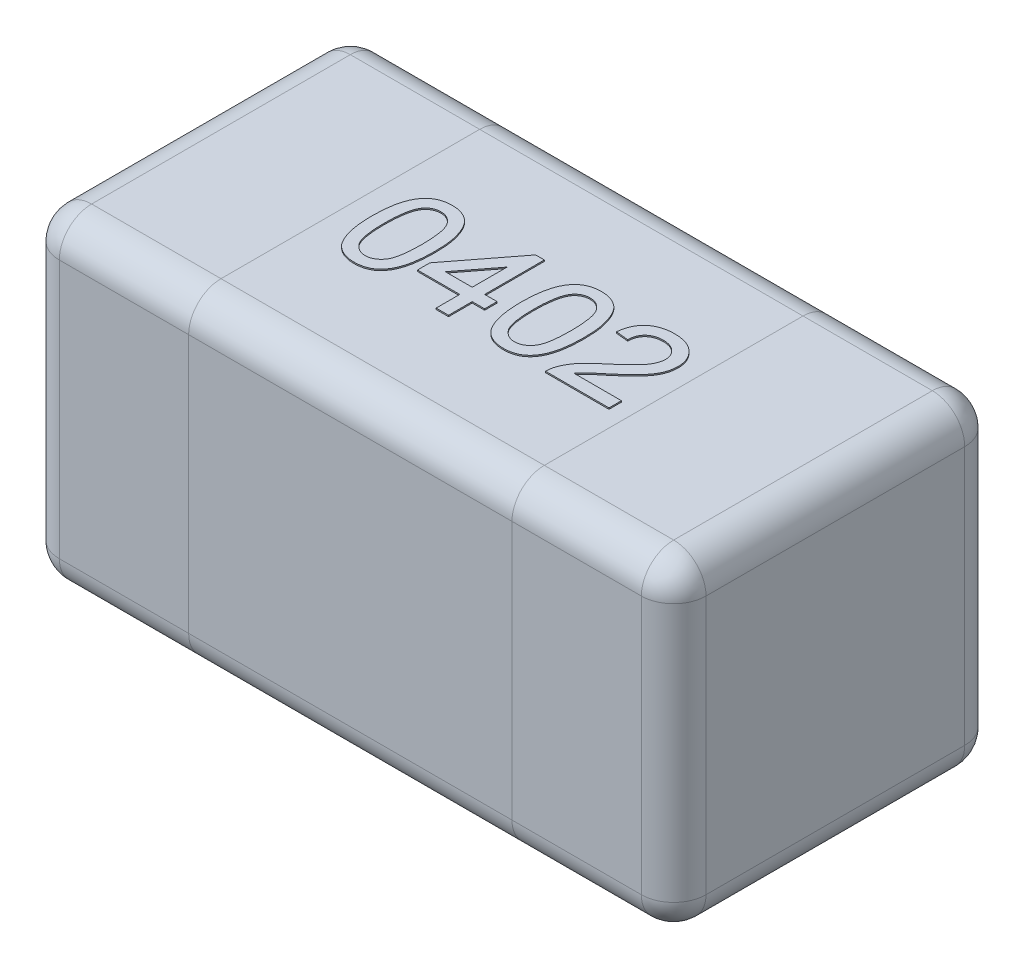
from build123d import *

# Parameters (mm, degrees)
SKETCH1_W      = 1
SKETCH1_H      = 0.5
EXTRUDE1_DEPTH = 0.5
FILLET1_R      = 0.05
EXTRUDE2_DEPTH = 0.002


with BuildPart() as part:
    # Sketch1 → Extrude1 (new body)
    with BuildSketch(Plane(origin=(0, 0, 0), x_dir=(1, 0, 0), z_dir=(0, 1, 0))):
        Rectangle(SKETCH1_W, SKETCH1_H)
    extrude(amount=EXTRUDE1_DEPTH)

    # Fillet1
    fillet1_edges = [part.edges().sort_by_distance(p)[0] for p in [
        (0.5, 0.5, 0),
        (0, 0.5, -0.25),
        (-0.5, 0.5, 0),
        (0, 0, -0.25),
        (0.5, 0, 0),
        (0, 0, 0.25),
        (-0.5, 0, 0),
        (0, 0.5, 0.25),
        (-0.5, 0.25, -0.25),
        (0.5, 0.25, -0.25),
        (0.5, 0.25, 0.25),
        (-0.5, 0.25, 0.25),
    ]]
    fillet(fillet1_edges, radius=FILLET1_R)

    # Sketch3 → Extrude2 (add)
    with BuildSketch(Plane(origin=(0, 0.5, 0), x_dir=(1, 0, 0), z_dir=(0, 1, 0))):
        with BuildLine():
            add(Edge.make_bspline(
                [(-0.215384615, -0.001021635), (-0.21536524, 0.001122003), (-0.215327293, 0.005320487), (-0.215091917, 0.011463622), (-0.21468097, 0.017297504), (-0.214067539, 0.022817065), (-0.213341122, 0.028034764), (-0.212396775, 0.032943155), (-0.211334247, 0.037553251), (-0.210059405, 0.041860246), (-0.20865877, 0.045901174), (-0.207069705, 0.04966955), (-0.205281792, 0.053161381), (-0.203382895, 0.056412877), (-0.201273053, 0.059373466), (-0.19907961, 0.062126232), (-0.196643162, 0.064570222), (-0.19406502, 0.06676832), (-0.191307221, 0.068708013), (-0.188384356, 0.070381735), (-0.185307672, 0.07185951), (-0.182018531, 0.072971978), (-0.178585214, 0.073878876), (-0.174981294, 0.074546001), (-0.171202799, 0.074939294), (-0.168620729, 0.074979536), (-0.167307692, 0.075)],
                knots=[0, 0, 0, 0, 6.431e-06, 1.2595e-05, 1.844e-05, 2.3971e-05, 2.9254e-05, 3.4239e-05, 3.8962e-05, 4.344e-05, 4.7707e-05, 5.1787e-05, 5.5698e-05, 5.947e-05, 6.3071e-05, 6.6596e-05, 7.0016e-05, 7.3406e-05, 7.6749e-05, 8.0114e-05, 8.3502e-05, 8.697e-05, 9.0512e-05, 9.4149e-05, 9.7955e-05, 0.000101893, 0.000101893, 0.000101893, 0.000101893], degree=3))
            add(Edge.make_bspline(
                [(-0.167307692, 0.075), (-0.165381297, 0.074943365), (-0.161596815, 0.074832104), (-0.156071453, 0.073924679), (-0.150864154, 0.072372388), (-0.145978304, 0.070278281), (-0.141497424, 0.067618363), (-0.137495809, 0.064384826), (-0.134016624, 0.060611623), (-0.131097837, 0.056254042), (-0.128546526, 0.051432296), (-0.126279998, 0.046124741), (-0.124231122, 0.040337325), (-0.122777195, 0.035156781), (-0.12174011, 0.030684751), (-0.121053643, 0.026996347), (-0.120483737, 0.023016538), (-0.120047112, 0.018754953), (-0.119688871, 0.014216372), (-0.119412219, 0.009397968), (-0.119271789, 0.004287698), (-0.119244699, 0.000781321), (-0.119230769, -0.001021635)],
                knots=[0, 0, 0, 0, 5.777e-06, 1.1349e-05, 1.674e-05, 2.2043e-05, 2.7258e-05, 3.2321e-05, 3.7425e-05, 4.2592e-05, 4.801e-05, 5.377e-05, 5.9891e-05, 6.6416e-05, 6.99e-05, 7.366e-05, 7.7668e-05, 8.1958e-05, 8.651e-05, 9.1325e-05, 9.6435e-05, 0.000101844, 0.000101844, 0.000101844, 0.000101844], degree=3))
            add(Edge.make_bspline(
                [(-0.119230769, -0.001021635), (-0.119250507, -0.003155203), (-0.119289069, -0.00732355), (-0.119518138, -0.013417428), (-0.119953848, -0.019207296), (-0.120489996, -0.024706416), (-0.121301077, -0.029900109), (-0.12217506, -0.034810441), (-0.123255962, -0.039415115), (-0.12451712, -0.043716149), (-0.12593747, -0.047736285), (-0.127495104, -0.051505906), (-0.129220334, -0.055022436), (-0.131164508, -0.058251575), (-0.133238671, -0.061236186), (-0.135458016, -0.063987464), (-0.137869594, -0.066465811), (-0.140470969, -0.068657315), (-0.143209405, -0.070631406), (-0.146139376, -0.072321652), (-0.149248057, -0.073721992), (-0.152514679, -0.074919212), (-0.155972386, -0.075796465), (-0.159593911, -0.076467989), (-0.163392598, -0.07686343), (-0.165984655, -0.07690292), (-0.167307692, -0.076923077)],
                knots=[0, 0, 0, 0, 6.401e-06, 1.2505e-05, 1.829e-05, 2.3818e-05, 2.9075e-05, 3.4055e-05, 3.8778e-05, 4.3256e-05, 4.7495e-05, 5.1563e-05, 5.5487e-05, 5.9233e-05, 6.2859e-05, 6.6384e-05, 6.9826e-05, 7.3215e-05, 7.6576e-05, 7.9941e-05, 8.3343e-05, 8.6794e-05, 9.0365e-05, 9.4031e-05, 9.7837e-05, 0.000101805, 0.000101805, 0.000101805, 0.000101805], degree=3))
            add(Edge.make_bspline(
                [(-0.167307692, -0.076923077), (-0.169042347, -0.076873596), (-0.172424447, -0.076777121), (-0.177363754, -0.076121636), (-0.181999557, -0.074967951), (-0.186370957, -0.073420697), (-0.190428817, -0.071351156), (-0.194192513, -0.068833154), (-0.197737673, -0.065925277), (-0.199778482, -0.063631029), (-0.200811298, -0.062469952)],
                knots=[0, 0, 0, 0, 5.204e-06, 1.0146e-05, 1.4912e-05, 1.9513e-05, 2.4028e-05, 2.8537e-05, 3.308e-05, 3.7736e-05, 3.7736e-05, 3.7736e-05, 3.7736e-05], degree=3))
            add(Edge.make_bspline(
                [(-0.200811298, -0.062469952), (-0.202000093, -0.060755098), (-0.204451439, -0.057218995), (-0.207320527, -0.051189611), (-0.209879805, -0.044552107), (-0.211888368, -0.037176254), (-0.213461574, -0.029120757), (-0.214597822, -0.020369808), (-0.215240826, -0.010927188), (-0.215335604, -0.004398023), (-0.215384615, -0.001021635)],
                knots=[0, 0, 0, 0, 6.251e-06, 1.2889e-05, 1.9965e-05, 2.7576e-05, 3.5785e-05, 4.4573e-05, 5.4032e-05, 6.4161e-05, 6.4161e-05, 6.4161e-05, 6.4161e-05], degree=3))
        make_face()
        with BuildLine():
            add(Edge.make_bspline(
                [(-0.196153846, -0.000961538), (-0.196134752, -0.003846584), (-0.1960982, -0.009369199), (-0.195716327, -0.017259208), (-0.195058949, -0.024377073), (-0.194189852, -0.030712939), (-0.193042293, -0.036275377), (-0.191601396, -0.041050211), (-0.189977162, -0.045094751), (-0.187967204, -0.048358867), (-0.185766521, -0.051019598), (-0.183494467, -0.053307912), (-0.181097587, -0.055252927), (-0.178591522, -0.056874673), (-0.175937387, -0.058102553), (-0.173164205, -0.058992522), (-0.170271373, -0.059504686), (-0.168301222, -0.059578275), (-0.167307692, -0.059615385)],
                knots=[0, 0, 0, 0, 8.655e-06, 1.6567e-05, 2.3689e-05, 3.0093e-05, 3.5745e-05, 4.0706e-05, 4.5043e-05, 4.8779e-05, 5.2153e-05, 5.5383e-05, 5.8438e-05, 6.1397e-05, 6.4314e-05, 6.7184e-05, 7.0113e-05, 7.3094e-05, 7.3094e-05, 7.3094e-05, 7.3094e-05], degree=3))
            add(Edge.make_bspline(
                [(-0.167307692, -0.059615385), (-0.166314411, -0.059577464), (-0.164344754, -0.059502268), (-0.161445238, -0.059001397), (-0.158682846, -0.058065613), (-0.156032668, -0.05684207), (-0.153508388, -0.055257289), (-0.15112328, -0.053304927), (-0.148839257, -0.051017971), (-0.14664846, -0.048326314), (-0.144653815, -0.045047107), (-0.142999112, -0.041005862), (-0.141580671, -0.036222665), (-0.140426814, -0.030663062), (-0.139554132, -0.024337213), (-0.138900728, -0.01723909), (-0.1385163, -0.009359233), (-0.138480352, -0.003846597), (-0.138461538, -0.000961538)],
                knots=[0, 0, 0, 0, 2.98e-06, 5.91e-06, 8.789e-06, 1.1706e-05, 1.4649e-05, 1.7704e-05, 2.0934e-05, 2.4331e-05, 2.8093e-05, 3.2402e-05, 3.7392e-05, 4.3044e-05, 4.9418e-05, 5.654e-05, 6.4422e-05, 7.3077e-05, 7.3077e-05, 7.3077e-05, 7.3077e-05], degree=3))
            add(Edge.make_bspline(
                [(-0.138461538, -0.000961538), (-0.13847975, 0.001863491), (-0.138514642, 0.007276142), (-0.138908985, 0.015014149), (-0.139526956, 0.022012544), (-0.140372243, 0.028277777), (-0.141495628, 0.033803048), (-0.142858142, 0.038600117), (-0.144481781, 0.042658756), (-0.146412281, 0.046019733), (-0.148561315, 0.048776646), (-0.150806184, 0.051162994), (-0.153203011, 0.053192505), (-0.15579426, 0.054820609), (-0.15849641, 0.056134103), (-0.161371551, 0.057038082), (-0.164391421, 0.057593459), (-0.166463918, 0.057658982), (-0.167518029, 0.057692308)],
                knots=[0, 0, 0, 0, 8.474e-06, 1.6237e-05, 2.3236e-05, 2.9547e-05, 3.5192e-05, 4.0137e-05, 4.4489e-05, 4.8272e-05, 5.1722e-05, 5.4953e-05, 5.8088e-05, 6.1114e-05, 6.4111e-05, 6.7076e-05, 7.0129e-05, 7.329e-05, 7.329e-05, 7.329e-05, 7.329e-05], degree=3))
            add(Edge.make_bspline(
                [(-0.167518029, 0.057692308), (-0.168511496, 0.057666233), (-0.170470487, 0.057614817), (-0.173338706, 0.057124054), (-0.176056884, 0.056303389), (-0.178656161, 0.055191718), (-0.181071649, 0.053695629), (-0.18339914, 0.051948838), (-0.185529622, 0.049820569), (-0.186813432, 0.048229508), (-0.187469952, 0.047415865)],
                knots=[0, 0, 0, 0, 2.979e-06, 5.873e-06, 8.697e-06, 1.1482e-05, 1.4327e-05, 1.72e-05, 2.0196e-05, 2.3331e-05, 2.3331e-05, 2.3331e-05, 2.3331e-05], degree=3))
            add(Edge.make_bspline(
                [(-0.187469952, 0.047415865), (-0.188184701, 0.046220876), (-0.189694102, 0.043697311), (-0.191383033, 0.03931125), (-0.192874969, 0.034298818), (-0.194103326, 0.028582894), (-0.194991956, 0.022173284), (-0.195693496, 0.01507743), (-0.196057919, 0.007285427), (-0.196120988, 0.001863295), (-0.196153846, -0.000961538)],
                knots=[0, 0, 0, 0, 4.171e-06, 8.807e-06, 1.4046e-05, 1.9857e-05, 2.6324e-05, 3.3449e-05, 4.1242e-05, 4.9717e-05, 4.9717e-05, 4.9717e-05, 4.9717e-05], degree=3))
        make_face(mode=Mode.SUBTRACT)
        Polygon((-0.042307692, -0.075), (-0.042307692, -0.038461538), (-0.107692308, -0.038461538), (-0.107692308, -0.019230769), (-0.036538462, 0.073076923), (-0.023076923, 0.073076923), (-0.023076923, -0.019230769), (-0.003846154, -0.019230769), (-0.003846154, -0.038461538), (-0.023076923, -0.038461538), (-0.023076923, -0.075), align=None)
        Polygon((-0.042307692, -0.019230769), (-0.042307692, 0.034795673), (-0.083954327, -0.019230769), align=None, mode=Mode.SUBTRACT)
        with BuildLine():
            add(Edge.make_bspline(
                [(0.015384615, -0.001021635), (0.01540399, 0.001122003), (0.015441938, 0.005320487), (0.015677314, 0.011463622), (0.016088261, 0.017297504), (0.016701692, 0.022817065), (0.017428109, 0.028034764), (0.018372456, 0.032943155), (0.019434984, 0.037553251), (0.020709826, 0.041860246), (0.022110461, 0.045901174), (0.023699525, 0.04966955), (0.025487439, 0.053161381), (0.027386336, 0.056412877), (0.029496178, 0.059373466), (0.031689621, 0.062126232), (0.034126069, 0.064570222), (0.036704211, 0.06676832), (0.03946201, 0.068708013), (0.042384875, 0.070381735), (0.045461558, 0.07185951), (0.0487507, 0.072971978), (0.052184016, 0.073878876), (0.055787937, 0.074546001), (0.059566432, 0.074939294), (0.062148502, 0.074979536), (0.063461538, 0.075)],
                knots=[0, 0, 0, 0, 6.431e-06, 1.2595e-05, 1.844e-05, 2.3971e-05, 2.9254e-05, 3.4239e-05, 3.8962e-05, 4.344e-05, 4.7707e-05, 5.1787e-05, 5.5698e-05, 5.947e-05, 6.3071e-05, 6.6596e-05, 7.0016e-05, 7.3406e-05, 7.6749e-05, 8.0114e-05, 8.3502e-05, 8.697e-05, 9.0512e-05, 9.4149e-05, 9.7955e-05, 0.000101893, 0.000101893, 0.000101893, 0.000101893], degree=3))
            add(Edge.make_bspline(
                [(0.063461538, 0.075), (0.065387934, 0.074943365), (0.069172416, 0.074832104), (0.074697778, 0.073924679), (0.079905076, 0.072372388), (0.084790927, 0.070278281), (0.089271807, 0.067618363), (0.093273422, 0.064384826), (0.096752607, 0.060611623), (0.099671394, 0.056254042), (0.102222704, 0.051432296), (0.104489233, 0.046124741), (0.106538109, 0.040337325), (0.107992036, 0.035156781), (0.10902912, 0.030684751), (0.109715588, 0.026996347), (0.110285494, 0.023016538), (0.110722119, 0.018754953), (0.111080359, 0.014216372), (0.111357012, 0.009397968), (0.111497442, 0.004287698), (0.111524532, 0.000781321), (0.111538462, -0.001021635)],
                knots=[0, 0, 0, 0, 5.777e-06, 1.1349e-05, 1.674e-05, 2.2043e-05, 2.7258e-05, 3.2321e-05, 3.7425e-05, 4.2592e-05, 4.801e-05, 5.377e-05, 5.9891e-05, 6.6416e-05, 6.99e-05, 7.366e-05, 7.7668e-05, 8.1958e-05, 8.651e-05, 9.1325e-05, 9.6435e-05, 0.000101844, 0.000101844, 0.000101844, 0.000101844], degree=3))
            add(Edge.make_bspline(
                [(0.111538462, -0.001021635), (0.111518724, -0.003155203), (0.111480162, -0.00732355), (0.111251093, -0.013417428), (0.110815383, -0.019207296), (0.110279235, -0.024706416), (0.109468154, -0.029900109), (0.108594171, -0.034810441), (0.107513269, -0.039415115), (0.106252111, -0.043716149), (0.10483176, -0.047736285), (0.103274126, -0.051505906), (0.101548897, -0.055022436), (0.099604723, -0.058251575), (0.097530559, -0.061236186), (0.095311215, -0.063987464), (0.092899636, -0.066465811), (0.090298262, -0.068657315), (0.087559826, -0.070631406), (0.084629855, -0.072321652), (0.081521174, -0.073721992), (0.078254552, -0.074919212), (0.074796845, -0.075796465), (0.07117532, -0.076467989), (0.067376633, -0.07686343), (0.064784575, -0.07690292), (0.063461538, -0.076923077)],
                knots=[0, 0, 0, 0, 6.401e-06, 1.2505e-05, 1.829e-05, 2.3818e-05, 2.9075e-05, 3.4055e-05, 3.8778e-05, 4.3256e-05, 4.7495e-05, 5.1563e-05, 5.5487e-05, 5.9233e-05, 6.2859e-05, 6.6384e-05, 6.9826e-05, 7.3215e-05, 7.6576e-05, 7.9941e-05, 8.3343e-05, 8.6794e-05, 9.0365e-05, 9.4031e-05, 9.7837e-05, 0.000101805, 0.000101805, 0.000101805, 0.000101805], degree=3))
            add(Edge.make_bspline(
                [(0.063461538, -0.076923077), (0.061726884, -0.076873596), (0.058344784, -0.076777121), (0.053405477, -0.076121636), (0.048769674, -0.074967951), (0.044398274, -0.073420697), (0.040340414, -0.071351156), (0.036576718, -0.068833154), (0.033031558, -0.065925277), (0.030990749, -0.063631029), (0.029957933, -0.062469952)],
                knots=[0, 0, 0, 0, 5.204e-06, 1.0146e-05, 1.4912e-05, 1.9513e-05, 2.4028e-05, 2.8537e-05, 3.308e-05, 3.7736e-05, 3.7736e-05, 3.7736e-05, 3.7736e-05], degree=3))
            add(Edge.make_bspline(
                [(0.029957933, -0.062469952), (0.028769138, -0.060755098), (0.026317792, -0.057218995), (0.023448703, -0.051189611), (0.020889426, -0.044552107), (0.018880862, -0.037176254), (0.017307656, -0.029120757), (0.016171409, -0.020369808), (0.015528405, -0.010927188), (0.015433627, -0.004398023), (0.015384615, -0.001021635)],
                knots=[0, 0, 0, 0, 6.251e-06, 1.2889e-05, 1.9965e-05, 2.7576e-05, 3.5785e-05, 4.4573e-05, 5.4032e-05, 6.4161e-05, 6.4161e-05, 6.4161e-05, 6.4161e-05], degree=3))
        make_face()
        with BuildLine():
            add(Edge.make_bspline(
                [(0.034615385, -0.000961538), (0.034634479, -0.003846584), (0.034671031, -0.009369199), (0.035052903, -0.017259208), (0.035710281, -0.024377073), (0.036579378, -0.030712939), (0.037726938, -0.036275377), (0.039167835, -0.041050211), (0.040792069, -0.045094751), (0.042802027, -0.048358867), (0.04500271, -0.051019598), (0.047274764, -0.053307912), (0.049671644, -0.055252927), (0.052177709, -0.056874673), (0.054831844, -0.058102553), (0.057605026, -0.058992522), (0.060497858, -0.059504686), (0.062468008, -0.059578275), (0.063461538, -0.059615385)],
                knots=[0, 0, 0, 0, 8.655e-06, 1.6567e-05, 2.3689e-05, 3.0093e-05, 3.5745e-05, 4.0706e-05, 4.5043e-05, 4.8779e-05, 5.2153e-05, 5.5383e-05, 5.8438e-05, 6.1397e-05, 6.4314e-05, 6.7184e-05, 7.0113e-05, 7.3094e-05, 7.3094e-05, 7.3094e-05, 7.3094e-05], degree=3))
            add(Edge.make_bspline(
                [(0.063461538, -0.059615385), (0.06445482, -0.059577464), (0.066424477, -0.059502268), (0.069323993, -0.059001397), (0.072086385, -0.058065613), (0.074736563, -0.05684207), (0.077260843, -0.055257289), (0.079645951, -0.053304927), (0.081929974, -0.051017971), (0.084120771, -0.048326314), (0.086115416, -0.045047107), (0.087770119, -0.041005862), (0.08918856, -0.036222665), (0.090342417, -0.030663062), (0.091215099, -0.024337213), (0.091868502, -0.01723909), (0.092252931, -0.009359233), (0.092288879, -0.003846597), (0.092307692, -0.000961538)],
                knots=[0, 0, 0, 0, 2.98e-06, 5.91e-06, 8.789e-06, 1.1706e-05, 1.4649e-05, 1.7704e-05, 2.0934e-05, 2.4331e-05, 2.8093e-05, 3.2402e-05, 3.7392e-05, 4.3044e-05, 4.9418e-05, 5.654e-05, 6.4422e-05, 7.3077e-05, 7.3077e-05, 7.3077e-05, 7.3077e-05], degree=3))
            add(Edge.make_bspline(
                [(0.092307692, -0.000961538), (0.092289481, 0.001863491), (0.092254589, 0.007276142), (0.091860246, 0.015014149), (0.091242275, 0.022012544), (0.090396988, 0.028277777), (0.089273602, 0.033803048), (0.087911089, 0.038600117), (0.08628745, 0.042658756), (0.084356949, 0.046019733), (0.082207916, 0.048776646), (0.079963047, 0.051162994), (0.07756622, 0.053192505), (0.074974971, 0.054820609), (0.07227282, 0.056134103), (0.06939768, 0.057038082), (0.06637781, 0.057593459), (0.064305312, 0.057658982), (0.063251202, 0.057692308)],
                knots=[0, 0, 0, 0, 8.474e-06, 1.6237e-05, 2.3236e-05, 2.9547e-05, 3.5192e-05, 4.0137e-05, 4.4489e-05, 4.8272e-05, 5.1722e-05, 5.4953e-05, 5.8088e-05, 6.1114e-05, 6.4111e-05, 6.7076e-05, 7.0129e-05, 7.329e-05, 7.329e-05, 7.329e-05, 7.329e-05], degree=3))
            add(Edge.make_bspline(
                [(0.063251202, 0.057692308), (0.062257734, 0.057666233), (0.060298744, 0.057614817), (0.057430524, 0.057124054), (0.054712347, 0.056303389), (0.052113069, 0.055191718), (0.049697582, 0.053695629), (0.047370091, 0.051948838), (0.045239608, 0.049820569), (0.043955798, 0.048229508), (0.043299279, 0.047415865)],
                knots=[0, 0, 0, 0, 2.979e-06, 5.873e-06, 8.697e-06, 1.1482e-05, 1.4327e-05, 1.72e-05, 2.0196e-05, 2.3331e-05, 2.3331e-05, 2.3331e-05, 2.3331e-05], degree=3))
            add(Edge.make_bspline(
                [(0.043299279, 0.047415865), (0.042584529, 0.046220876), (0.041075129, 0.043697311), (0.039386197, 0.03931125), (0.037894262, 0.034298818), (0.036665905, 0.028582894), (0.035777274, 0.022173284), (0.035075735, 0.01507743), (0.034711312, 0.007285427), (0.034648242, 0.001863295), (0.034615385, -0.000961538)],
                knots=[0, 0, 0, 0, 4.171e-06, 8.807e-06, 1.4046e-05, 1.9857e-05, 2.6324e-05, 3.3449e-05, 4.1242e-05, 4.9717e-05, 4.9717e-05, 4.9717e-05, 4.9717e-05], degree=3))
        make_face(mode=Mode.SUBTRACT)
        with BuildLine():
            Line((0.225, -0.055769231), (0.225, -0.075))
            Line((0.225, -0.075), (0.126923077, -0.075))
            add(Edge.make_bspline(
                [(0.126923077, -0.075), (0.126921069, -0.073857061), (0.12691706, -0.071575015), (0.127303219, -0.068200013), (0.127908021, -0.064869783), (0.128591871, -0.062734239), (0.128936298, -0.061658654)],
                knots=[0, 0, 0, 0, 3.426e-06, 6.841e-06, 1.0176e-05, 1.3561e-05, 1.3561e-05, 1.3561e-05, 1.3561e-05], degree=3))
            add(Edge.make_bspline(
                [(0.128936298, -0.061658654), (0.129572684, -0.059901276), (0.130868472, -0.056322964), (0.133493751, -0.051159961), (0.136581699, -0.046028182), (0.139588252, -0.04185019), (0.142341605, -0.038512266), (0.14465065, -0.035900727), (0.147209495, -0.033227509), (0.150016092, -0.030493101), (0.153043427, -0.027679792), (0.156295632, -0.0247782), (0.159811111, -0.021842401), (0.162265283, -0.019896431), (0.163521635, -0.01890024)],
                knots=[0, 0, 0, 0, 5.603e-06, 1.1408e-05, 1.7339e-05, 2.356e-05, 2.6827e-05, 3.0318e-05, 3.4016e-05, 3.7925e-05, 4.2071e-05, 4.6413e-05, 5.0999e-05, 5.5809e-05, 5.5809e-05, 5.5809e-05, 5.5809e-05], degree=3))
            add(Edge.make_bspline(
                [(0.163521635, -0.01890024), (0.1654517, -0.017275735), (0.169168165, -0.014147648), (0.174416395, -0.009505855), (0.179209799, -0.005195689), (0.183472047, -0.001141602), (0.187238, 0.002617081), (0.1905165, 0.006071846), (0.193335758, 0.009211911), (0.195661355, 0.012150933), (0.197623532, 0.014926186), (0.199286304, 0.017633275), (0.200672004, 0.020319486), (0.201826106, 0.022976319), (0.202738903, 0.025615135), (0.203361104, 0.028243623), (0.203783059, 0.030835702), (0.203825276, 0.0325605), (0.203846154, 0.033413462)],
                knots=[0, 0, 0, 0, 7.568e-06, 1.4572e-05, 2.1018e-05, 2.6906e-05, 3.2217e-05, 3.6978e-05, 4.1193e-05, 4.4872e-05, 4.8215e-05, 5.1384e-05, 5.4395e-05, 5.7275e-05, 6.0069e-05, 6.2758e-05, 6.5371e-05, 6.7928e-05, 6.7928e-05, 6.7928e-05, 6.7928e-05], degree=3))
            add(Edge.make_bspline(
                [(0.203846154, 0.033413462), (0.203825274, 0.034256471), (0.203784308, 0.035910411), (0.20339563, 0.03833094), (0.202854559, 0.040661969), (0.201979812, 0.042861531), (0.2009386, 0.044994766), (0.199602994, 0.046994266), (0.198057972, 0.048909863), (0.196289053, 0.050691052), (0.194356979, 0.052362092), (0.192198162, 0.053751132), (0.189954391, 0.055001681), (0.18754826, 0.056007195), (0.184983678, 0.056745562), (0.182279313, 0.057281426), (0.179435596, 0.057621193), (0.177494958, 0.057668243), (0.176502404, 0.057692308)],
                knots=[0, 0, 0, 0, 2.527e-06, 4.958e-06, 7.341e-06, 9.69e-06, 1.2042e-05, 1.445e-05, 1.6886e-05, 1.9414e-05, 2.1973e-05, 2.4531e-05, 2.71e-05, 2.9672e-05, 3.2335e-05, 3.5092e-05, 3.7936e-05, 4.0913e-05, 4.0913e-05, 4.0913e-05, 4.0913e-05], degree=3))
            add(Edge.make_bspline(
                [(0.176502404, 0.057692308), (0.175459753, 0.057668362), (0.173419208, 0.0576215), (0.170436479, 0.057280378), (0.167604894, 0.05675919), (0.164931212, 0.055962339), (0.162418689, 0.054958502), (0.160077555, 0.053694939), (0.157870321, 0.052268604), (0.155866501, 0.050579931), (0.154054473, 0.048707538), (0.152445813, 0.046669068), (0.151127759, 0.044425183), (0.150039255, 0.042025221), (0.149164007, 0.039461638), (0.148528606, 0.036714835), (0.148182182, 0.033792744), (0.148112518, 0.031791696), (0.148076923, 0.030769231)],
                knots=[0, 0, 0, 0, 3.127e-06, 6.12e-06, 8.996e-06, 1.1753e-05, 1.4476e-05, 1.7098e-05, 1.9723e-05, 2.2347e-05, 2.4939e-05, 2.753e-05, 3.0117e-05, 3.2725e-05, 3.5424e-05, 3.823e-05, 4.1167e-05, 4.4236e-05, 4.4236e-05, 4.4236e-05, 4.4236e-05], degree=3))
            Line((0.148076923, 0.030769231), (0.128846154, 0.032692308))
            add(Edge.make_bspline(
                [(0.128846154, 0.032692308), (0.129042912, 0.034368316), (0.129425688, 0.037628847), (0.13037913, 0.042351176), (0.131717678, 0.046744295), (0.133319362, 0.050869455), (0.135327225, 0.054656431), (0.137596941, 0.058183555), (0.140273966, 0.06133896), (0.143231368, 0.064222108), (0.14650155, 0.066762921), (0.150053792, 0.068982673), (0.15388647, 0.070839359), (0.157978237, 0.072376617), (0.162338487, 0.073542974), (0.166961051, 0.074379362), (0.171853364, 0.074894921), (0.17520906, 0.074964474), (0.176923077, 0.075)],
                knots=[0, 0, 0, 0, 5.061e-06, 9.846e-06, 1.4428e-05, 1.8825e-05, 2.3099e-05, 2.7266e-05, 3.1383e-05, 3.5484e-05, 3.9638e-05, 4.3781e-05, 4.8028e-05, 5.2392e-05, 5.6875e-05, 6.1549e-05, 6.6473e-05, 7.1615e-05, 7.1615e-05, 7.1615e-05, 7.1615e-05], degree=3))
            add(Edge.make_bspline(
                [(0.176923077, 0.075), (0.178657609, 0.074970298), (0.182036489, 0.074912439), (0.186960059, 0.07432042), (0.191605584, 0.073398356), (0.195990093, 0.072113282), (0.200087683, 0.070428166), (0.203901505, 0.068369335), (0.207449145, 0.065956873), (0.210671327, 0.063161818), (0.213576854, 0.060110548), (0.216123119, 0.056854184), (0.21825192, 0.053406639), (0.220064461, 0.049814905), (0.22140889, 0.046003091), (0.222354317, 0.042023019), (0.222996763, 0.037871287), (0.223049848, 0.035038552), (0.223076923, 0.03359375)],
                knots=[0, 0, 0, 0, 5.201e-06, 1.0132e-05, 1.4853e-05, 1.9397e-05, 2.3817e-05, 2.8119e-05, 3.2378e-05, 3.666e-05, 4.089e-05, 4.5001e-05, 4.9037e-05, 5.3028e-05, 5.7048e-05, 6.1129e-05, 6.5289e-05, 6.962e-05, 6.962e-05, 6.962e-05, 6.962e-05], degree=3))
            add(Edge.make_bspline(
                [(0.223076923, 0.03359375), (0.223035579, 0.03210938), (0.222952801, 0.029137364), (0.222306703, 0.024695077), (0.221201221, 0.020300998), (0.219735648, 0.01590165), (0.21773337, 0.011479571), (0.215203832, 0.006973759), (0.212065664, 0.002367569), (0.209047626, -0.001548204), (0.206238322, -0.00483061), (0.20374814, -0.007532221), (0.200867143, -0.010402503), (0.197703409, -0.013540859), (0.194127905, -0.016835902), (0.190243364, -0.020386306), (0.185964751, -0.024098636), (0.18299456, -0.026634721), (0.181460337, -0.027944712)],
                knots=[0, 0, 0, 0, 4.452e-06, 8.914e-06, 1.3432e-05, 1.8031e-05, 2.2806e-05, 2.7972e-05, 3.3514e-05, 3.9512e-05, 4.2794e-05, 4.6473e-05, 5.0531e-05, 5.4993e-05, 5.9841e-05, 6.5116e-05, 7.0781e-05, 7.6833e-05, 7.6833e-05, 7.6833e-05, 7.6833e-05], degree=3))
            add(Edge.make_bspline(
                [(0.181460337, -0.027944712), (0.180146506, -0.02901431), (0.177641234, -0.031053868), (0.174076998, -0.034010672), (0.170884527, -0.03672198), (0.167989166, -0.039099356), (0.16549636, -0.04125779), (0.163318306, -0.043102752), (0.161534132, -0.044727006), (0.158817151, -0.047194282), (0.155375862, -0.050711133), (0.152840174, -0.05412836), (0.151622596, -0.055769231)],
                knots=[0, 0, 0, 0, 5.082e-06, 9.692e-06, 1.3893e-05, 1.7648e-05, 2.093e-05, 2.3785e-05, 2.621e-05, 2.8167e-05, 3.4797e-05, 4.0922e-05, 4.0922e-05, 4.0922e-05, 4.0922e-05], degree=3))
            Line((0.151622596, -0.055769231), (0.225, -0.055769231))
        make_face()
    extrude(amount=EXTRUDE2_DEPTH)


solid = part.part
